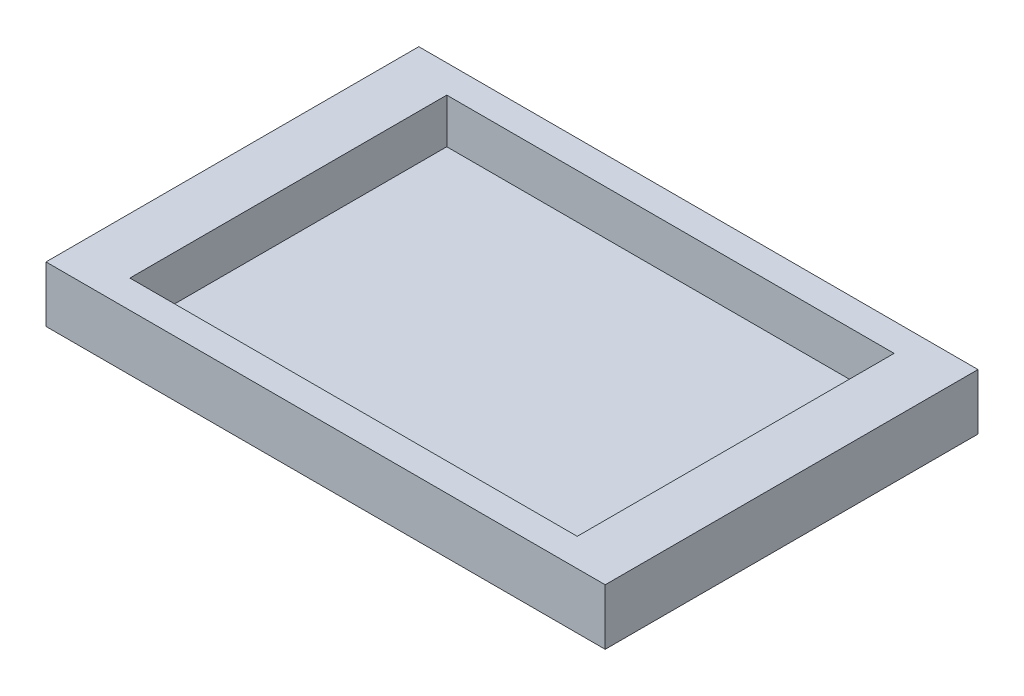
from build123d import *

# Parameters (mm, degrees)
SKETCH_1_W          = 150
SKETCH_1_H          = 100
EXTRUDE_1_DEPTH     = 15
SKETCH_2_W          = 120
SKETCH_2_H          = 85
CUT_EXTRUDE_1_DEPTH = 12


with BuildPart() as part:
    # Эскиз1 → Бобышка-Вытянуть1 (new body)
    with BuildSketch(Plane(origin=(0, 0, 0), x_dir=(1, 0, 0), z_dir=(0, 1, 0))):
        Rectangle(SKETCH_1_W, SKETCH_1_H)
    extrude(amount=EXTRUDE_1_DEPTH)

    # Эскиз2 → Вырез-Вытянуть1 (cut)
    with BuildSketch(Plane(origin=(0, 15, 0), x_dir=(1, 0, 0), z_dir=(0, 1, 0))):
        Rectangle(SKETCH_2_W, SKETCH_2_H)
    extrude(amount=-CUT_EXTRUDE_1_DEPTH, mode=Mode.SUBTRACT)


solid = part.part
